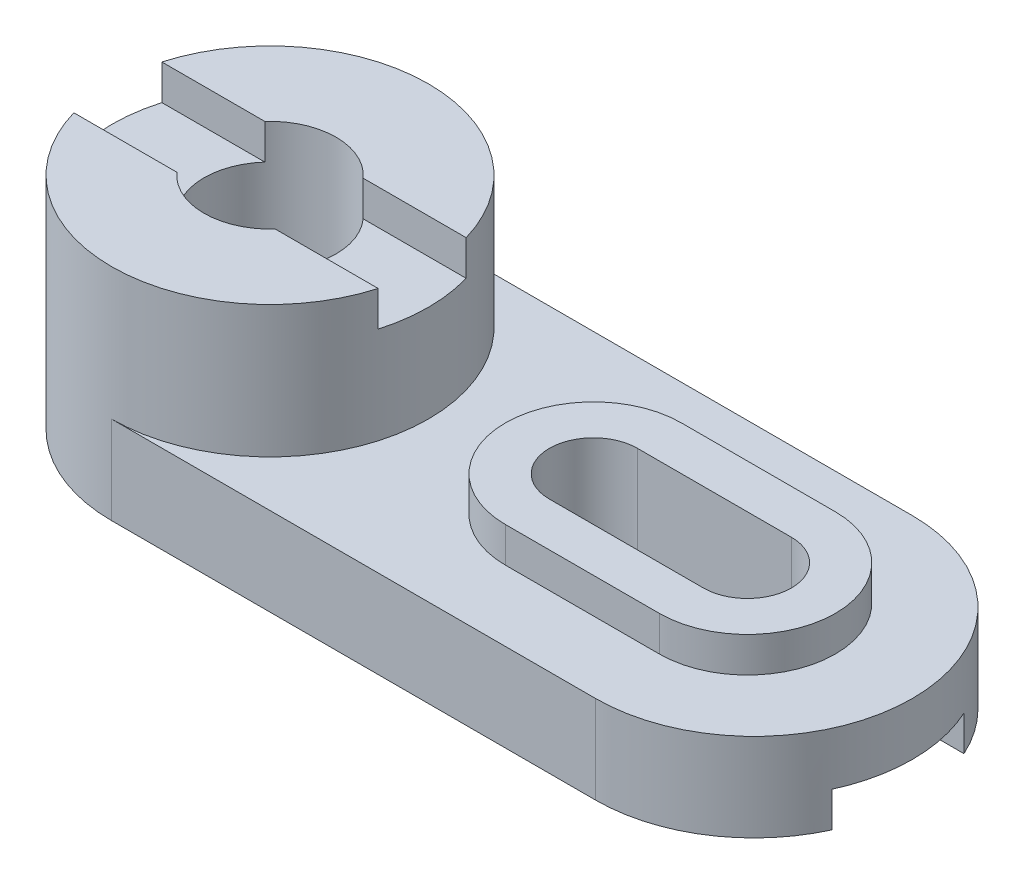
from build123d import *

# Parameters (mm, degrees)
BOSS_EXTRUDE1_DEPTH     = 20
SKETCH3_R               = 36
BOSS_EXTRUDE2_DEPTH     = 30
BOSS_EXTRUDE3_DEPTH     = 8
SKETCH6_W               = 30
SKETCH6_H               = 8
SKETCH6_W_2             = 20
CUT_EXTRUDE1_DEPTH      = 92
CUT_EXTRUDE1_DEPTH_BACK = 92
SKETCH7_R               = 15
CUT_EXTRUDE2_DEPTH      = 51
CUT_EXTRUDE2_DEPTH_BACK = 1


with BuildPart() as part:
    # Sketch2 → Boss-Extrude1 (new body)
    with BuildSketch(Plane(origin=(0, 0, 0), x_dir=(1, 0, 0), z_dir=(0, 1, 0))):
        with BuildLine():
            Line((-55, 36), (55, 36))
            ThreePointArc((55, 36), (91, 0), (55, -36))
            Line((55, -36), (-55, -36))
            ThreePointArc((-55, -36), (-91, 0), (-55, 36))
        make_face()
    extrude(amount=BOSS_EXTRUDE1_DEPTH)

    # Sketch3 → Boss-Extrude2 (add)
    with BuildSketch(Plane(origin=(0, 20, 0), x_dir=(1, 0, 0), z_dir=(0, 1, 0))):
        with Locations((-55, 0)):
            Circle(SKETCH3_R)
    extrude(amount=BOSS_EXTRUDE2_DEPTH)

    # Sketch4 → Boss-Extrude3 (add)
    with BuildSketch(Plane(origin=(0, 20, 0), x_dir=(1, 0, 0), z_dir=(0, 1, 0))):
        with BuildLine():
            Line((18.5, 20), (53.5, 20))
            ThreePointArc((53.5, 20), (73.5, 0), (53.5, -20))
            Line((53.5, -20), (18.5, -20))
            ThreePointArc((18.5, -20), (-1.5, 0), (18.5, 20))
        make_face()
    extrude(amount=BOSS_EXTRUDE3_DEPTH)

    # Sketch6 → Cut-Extrude1 (cut, two sides)
    with BuildSketch(Plane(origin=(0, 0, 0), x_dir=(0, 0, -1), z_dir=(1, 0, 0))) as cut_extrude1_sk:
        with Locations((0, 4)):
            Rectangle(SKETCH6_W, SKETCH6_H)
        with Locations((0, 46)):
            Rectangle(SKETCH6_W_2, SKETCH6_H)
    extrude(amount=CUT_EXTRUDE1_DEPTH, mode=Mode.SUBTRACT)
    extrude(cut_extrude1_sk.sketch, amount=-CUT_EXTRUDE1_DEPTH_BACK, mode=Mode.SUBTRACT)

    # Sketch7 → Cut-Extrude2 (cut, two sides)
    with BuildSketch(Plane(origin=(0, 0, 0), x_dir=(1, 0, 0), z_dir=(0, 1, 0))) as cut_extrude2_sk:
        with Locations((-55, 0)):
            Circle(SKETCH7_R)
        with BuildLine():
            Line((18.5, 10), (53.5, 10))
            ThreePointArc((53.5, 10), (63.5, 0), (53.5, -10))
            Line((53.5, -10), (18.5, -10))
            ThreePointArc((18.5, -10), (8.5, 0), (18.5, 10))
        make_face()
    extrude(amount=CUT_EXTRUDE2_DEPTH, mode=Mode.SUBTRACT)
    extrude(cut_extrude2_sk.sketch, amount=-CUT_EXTRUDE2_DEPTH_BACK, mode=Mode.SUBTRACT)


solid = part.part
